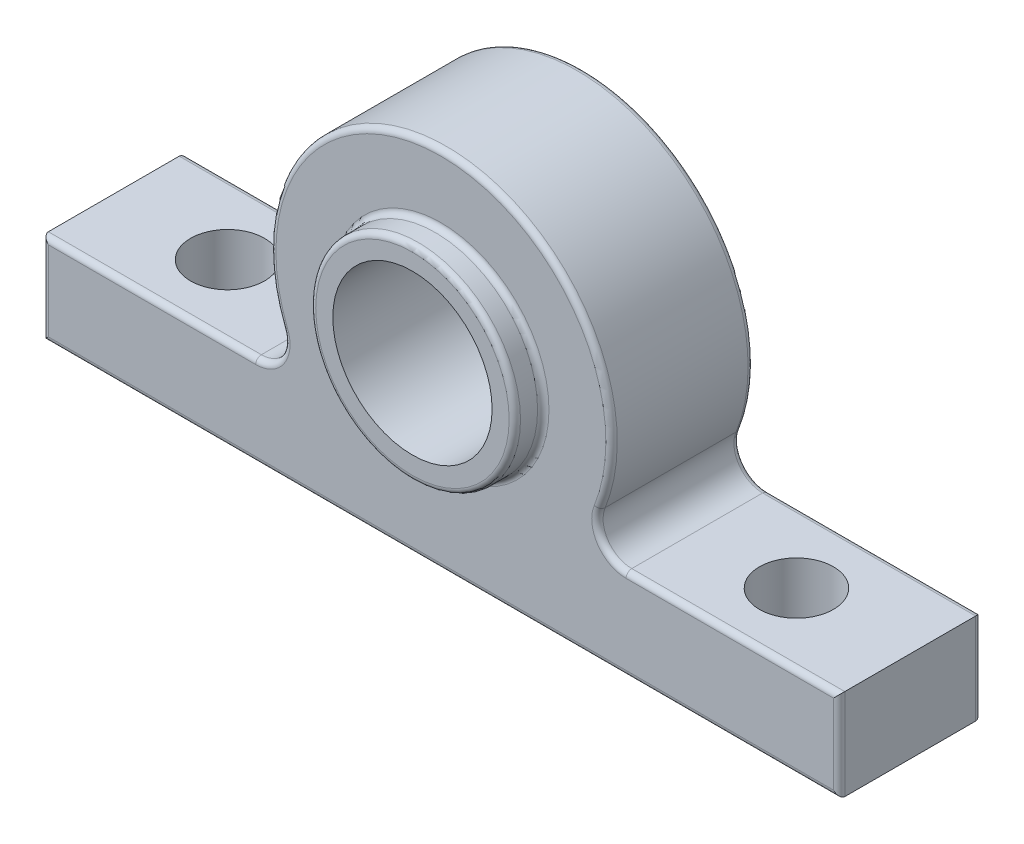
from build123d import *

# Parameters (mm, degrees)
SKETCH_1_R          = 14
EXTRUDE_1_DEPTH     = 25
SKETCH_2_R          = 18
CUT_EXTRUDE_1_DEPTH = 5
SKETCH_3_R          = 18
CUT_EXTRUDE_2_DEPTH = 5
SKETCH_4_R          = 18
SKETCH_4_R_2        = 14
EXTRUDE_2_DEPTH     = 10
FILLET_2_R          = 1
SKETCH_5_R          = 18
SKETCH_5_R_2        = 14
EXTRUDE_3_DEPTH     = 10
FILLET_3_R          = 1
SKETCH_6_R          = 6.5
CUT_EXTRUDE_3_DEPTH = 16
FILLET_4_R          = 1
FILLET_5_R          = 1


with BuildPart() as part:
    # Эскиз1 → Бобышка-Вытянуть1 (new body)
    with BuildSketch(Plane.XY):
        with BuildLine():
            Line((-32.553795133, 16), (-70, 16))
            Line((-70, 16), (-70, 0))
            Line((-70, 0), (70, 0))
            Line((70, 0), (70, 16))
            Line((70, 16), (32.553795133, 16))
            ThreePointArc((32.553795133, 16), (28.398794531, 18.187880588), (27.851681109, 22.851732898))
            ThreePointArc((27.851681109, 22.851732898), (27.871894986, 22.903328476), (27.892674994, 22.954698661))
            ThreePointArc((27.892674994, 22.954698661), (0, 64), (-27.892674994, 22.954698661))
            ThreePointArc((-27.892674994, 22.954698661), (-27.871894986, 22.903328476), (-27.851681109, 22.851732898))
            ThreePointArc((-27.851681109, 22.851732898), (-28.398794531, 18.187880588), (-32.553795133, 16))
        make_face()
        with Locations((0, 34)):
            Circle(SKETCH_1_R, mode=Mode.SUBTRACT)
    extrude(amount=EXTRUDE_1_DEPTH)

    # Эскиз2 → Вырез-Вытянуть1 (cut)
    with BuildSketch(Plane.XY.offset(25)):
        with Locations((0, 33.892664785)):
            Circle(SKETCH_2_R)
    extrude(amount=-CUT_EXTRUDE_1_DEPTH, mode=Mode.SUBTRACT)

    # Эскиз3 → Вырез-Вытянуть2 (cut)
    with BuildSketch(Plane(origin=(0, 0, 0), x_dir=(-1, 0, 0), z_dir=(0, 0, -1))):
        with Locations((0, 34)):
            Circle(SKETCH_3_R)
    extrude(amount=-CUT_EXTRUDE_2_DEPTH, mode=Mode.SUBTRACT)

    # Эскиз4 → Бобышка-Вытянуть2 (add)
    with BuildSketch(Plane.XY.offset(20)):
        with Locations((0, 33.892664785)):
            Circle(SKETCH_4_R)
        with Locations((0, 34)):
            Circle(SKETCH_4_R_2, mode=Mode.SUBTRACT)
    extrude(amount=EXTRUDE_2_DEPTH)

    # Скругление2
    fillet_2_edges = [part.edges().sort_by_distance(p)[0] for p in [
        (-18, 33.892664785, 30),
    ]]
    fillet(fillet_2_edges, radius=FILLET_2_R)

    # Эскиз5 → Бобышка-Вытянуть3 (add)
    with BuildSketch(Plane(origin=(0, 0, 5), x_dir=(-1, 0, 0), z_dir=(0, 0, -1))):
        with Locations((0, 34)):
            Circle(SKETCH_5_R)
        with Locations((0, 34)):
            Circle(SKETCH_5_R_2, mode=Mode.SUBTRACT)
    extrude(amount=EXTRUDE_3_DEPTH)

    # Скругление3
    fillet_3_edges = [part.edges().sort_by_distance(p)[0] for p in [
        (18, 34, -5),
    ]]
    fillet(fillet_3_edges, radius=FILLET_3_R)

    # Эскиз6 → Вырез-Вытянуть3 (cut)
    with BuildSketch(Plane(origin=(0, 16, 0), x_dir=(1, 0, 0), z_dir=(0, 1, 0))):
        with Locations((50, -12.5)):
            Circle(SKETCH_6_R)
        with Locations((-50, -12.5)):
            Circle(SKETCH_6_R)
    extrude(amount=-CUT_EXTRUDE_3_DEPTH, mode=Mode.SUBTRACT)

    # Скругление4
    fillet_4_edges = [part.edges().sort_by_distance(p)[0] for p in [
        (-51.276897566, 16, 25),
        (-70, 8, 25),
        (0, 0, 25),
        (70, 8, 25),
        (51.276897566, 16, 25),
        (28.367690905, 18.233741999, 25),
        (-18, 33.892664785, 25),
        (0, 64, 25),
        (-28.367690905, 18.233741999, 25),
    ]]
    fillet(fillet_4_edges, radius=FILLET_4_R)

    # Скругление5
    fillet_5_edges = [part.edges().sort_by_distance(p)[0] for p in [
        (0, 64, 0),
        (28.367690905, 18.233741999, 0),
        (51.276897566, 16, 0),
        (70, 8, 0),
        (0, 0, 0),
        (-70, 8, 0),
        (-51.276897566, 16, 0),
        (-28.367690905, 18.233741999, 0),
        (18, 34, 0),
    ]]
    fillet(fillet_5_edges, radius=FILLET_5_R)


solid = part.part
